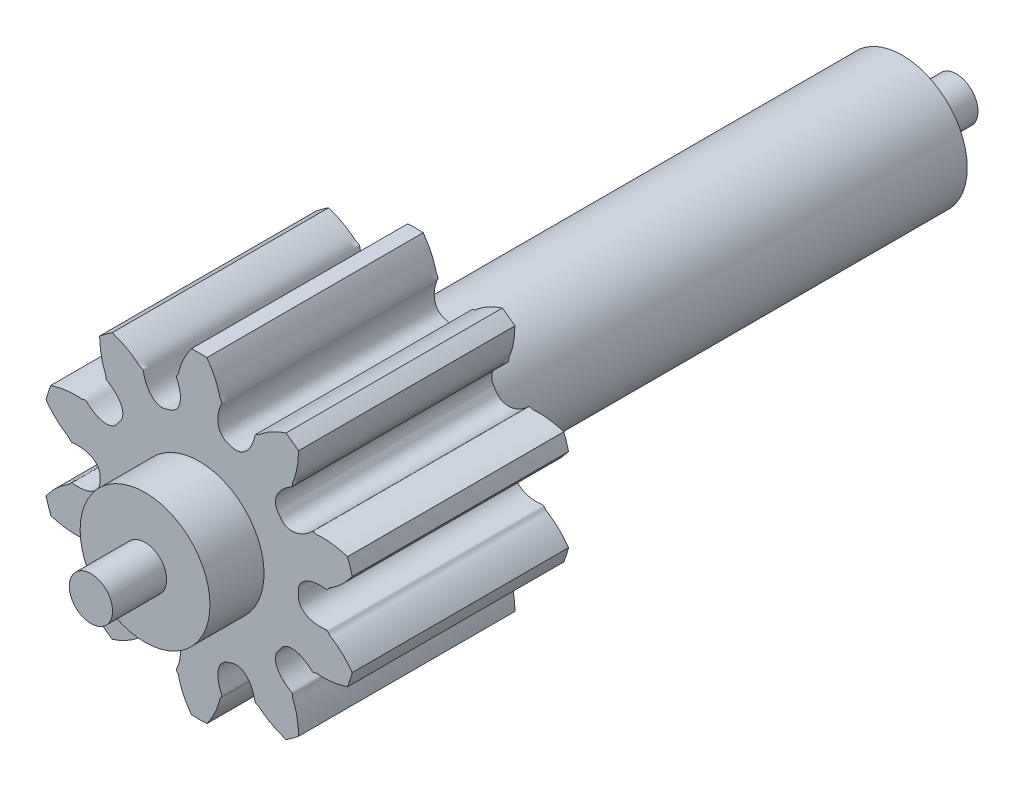
from build123d import *

# Parameters (mm, degrees)
SKETCHREVOLVEENGRANAJE_10D_W       = 1
SKETCHREVOLVEENGRANAJE_10D_H       = 0.733333333
TOOTHEXTRUDECUTENGRANAJE_10D_DEPTH = 0.5
PATTERNENGRANAJE_10D_COUNT         = 10
CROQUIS1_R                         = 0.3
SALIENTE_EXTRUIR1_DEPTH            = 0.25
CROQUIS2_R                         = 0.1
SALIENTE_EXTRUIR2_DEPTH            = 0.25
SALIENTE_EXTRUIR3_START            = 2.25
CROQUIS3_R                         = 0.3
SALIENTE_EXTRUIR3_DEPTH            = 2.25
SALIENTE_EXTRUIR4_START            = 0.25
CROQUIS4_R                         = 0.1
SALIENTE_EXTRUIR4_DEPTH            = 0.25


with BuildPart() as part:
    # SketchRevolveEngranaje 10d → Engranaje 10d (revolve)
    with BuildSketch(Plane(origin=(0, 0, 0), x_dir=(0, 0, -1), z_dir=(1, 0, 0))):
        with Locations((0, 0.366666667)):
            Rectangle(SKETCHREVOLVEENGRANAJE_10D_W, SKETCHREVOLVEENGRANAJE_10D_H)
    revolve(axis=Axis((0, 0, 0), (0, 0, -1)))

    # SketchToothEngranaje 10d → ToothExtrudeCutEngranaje 10d (cut, symmetric)
    with BuildSketch(Plane.XY):
        with BuildLine():
            ThreePointArc((0.712289976, 0.198547415), (0.739444444, 0), (0.712289976, -0.198547415))
            add(Edge.make_bspline(
                [(0.712289976, -0.198547415), (0.705362028, -0.188790946), (0.694695176, -0.174926641), (0.679771555, -0.157850696), (0.669044497, -0.146536064), (0.658544784, -0.136325123), (0.648345251, -0.127175151), (0.638506483, -0.11905948), (0.62911784, -0.11188103), (0.620160338, -0.10576032), (0.611956853, -0.100088888), (0.599411832, -0.094794728), (0.593159303, -0.07860585), (0.580817578, -0.081825839), (0.574358038, -0.082098325), (0.567911869, -0.082518366), (0.561630057, -0.082646483), (0.555476394, -0.082600496), (0.549462764, -0.082353409), (0.543588166, -0.081915249), (0.537854517, -0.081285814), (0.532262567, -0.080466784), (0.526812987, -0.079458409), (0.521506135, -0.078260171), (0.51634221, -0.07687038), (0.511321348, -0.075286016), (0.50644381, -0.073502465), (0.501710247, -0.071513259), (0.497122075, -0.069309806), (0.492682008, -0.06688113), (0.488394785, -0.064213688), (0.484268128, -0.06129133), (0.480313974, -0.058095519), (0.476549972, -0.054605987), (0.473001159, -0.050802046), (0.469701647, -0.04666479), (0.466695797, -0.042180402), (0.464038833, -0.037344546), (0.461793938, -0.03216766), (0.460033669, -0.026679635), (0.45881249, -0.020934905), (0.458302724, -0.015678249), (0.4581106, -0.008685464), (0.458496912, 0), (0.4581106, 0.008685464), (0.458302724, 0.015678249), (0.45881249, 0.020934905), (0.460033669, 0.026679635), (0.461793938, 0.03216766), (0.464038833, 0.037344546), (0.466695797, 0.042180402), (0.469701647, 0.04666479), (0.473001159, 0.050802046), (0.476549972, 0.054605987), (0.480313974, 0.058095519), (0.484268128, 0.06129133), (0.488394785, 0.064213688), (0.492682008, 0.06688113), (0.497122075, 0.069309806), (0.501710247, 0.071513259), (0.50644381, 0.073502465), (0.511321348, 0.075286016), (0.51634221, 0.07687038), (0.521506135, 0.078260171), (0.526812987, 0.079458409), (0.532262567, 0.080466784), (0.537854517, 0.081285814), (0.543588166, 0.081915249), (0.549462764, 0.082353409), (0.555476394, 0.082600496), (0.561630057, 0.082646483), (0.567911869, 0.082518366), (0.574358038, 0.082098325), (0.580817578, 0.081825839), (0.593159303, 0.07860585), (0.599411832, 0.094794728), (0.611956853, 0.100088888), (0.620160338, 0.10576032), (0.62911784, 0.11188103), (0.638506483, 0.11905948), (0.648345251, 0.127175151), (0.658544784, 0.136325123), (0.669044497, 0.146536064), (0.679771555, 0.157850696), (0.694695176, 0.174926641), (0.705362028, 0.188790946), (0.712289976, 0.198547415)],
                knots=[0, 0, 0, 0, 0.051263919, 0.074872303, 0.097131636, 0.118041919, 0.137603151, 0.155815333, 0.172678465, 0.188192546, 0.202357576, 0.215173557, 0.246662628, 0.256263074, 0.265651691, 0.27483298, 0.283811953, 0.292594197, 0.301185954, 0.309594215, 0.317826822, 0.325892584, 0.333801417, 0.341564491, 0.349194395, 0.356705321, 0.364113255, 0.371436161, 0.37869416, 0.385909665, 0.393107425, 0.400314445, 0.407559671, 0.41487336, 0.422285995, 0.42982663, 0.43752059, 0.445386581, 0.453433445, 0.461657142, 0.47003875, 0.478544424, 0.484242756, 0.5, 0.515757244, 0.521455576, 0.52996125, 0.538342858, 0.546566555, 0.554613419, 0.56247941, 0.57017337, 0.577714005, 0.58512664, 0.592440329, 0.599685555, 0.606892575, 0.614090335, 0.62130584, 0.628563839, 0.635886745, 0.643294679, 0.650805605, 0.658435509, 0.666198583, 0.674107416, 0.682173178, 0.690405785, 0.698814046, 0.707405803, 0.716188047, 0.72516702, 0.734348309, 0.743736926, 0.753337372, 0.784826443, 0.797642424, 0.811807454, 0.827321535, 0.844184667, 0.862396849, 0.881958081, 0.902868364, 0.925127697, 0.948736081, 1, 1, 1, 1], degree=3))
        make_face()
    toothextrudecutengranaje_10d = extrude(amount=TOOTHEXTRUDECUTENGRANAJE_10D_DEPTH, both=True, mode=Mode.SUBTRACT)

    # PatternEngranaje 10d: ToothExtrudeCutEngranaje 10d ×10 about axis
    patternengranaje_10d_axis = Axis((0, 0, 55), (0, 0, -1))
    for i in range(1, PATTERNENGRANAJE_10D_COUNT):
        add(toothextrudecutengranaje_10d.rotate(patternengranaje_10d_axis, i * 360 / PATTERNENGRANAJE_10D_COUNT), mode=Mode.SUBTRACT)

    # Croquis1 → Saliente-Extruir1 (add)
    with BuildSketch(Plane.XY.offset(0.5)):
        Circle(CROQUIS1_R)
    extrude(amount=SALIENTE_EXTRUIR1_DEPTH)

    # Croquis2 → Saliente-Extruir2 (add)
    with BuildSketch(Plane.XY.offset(0.75)):
        Circle(CROQUIS2_R)
    extrude(amount=SALIENTE_EXTRUIR2_DEPTH)

    # Croquis3 → Saliente-Extruir3 (add)
    with BuildSketch(Plane(origin=(0, 0, -0.5), x_dir=(-1, 0, 0), z_dir=(0, 0, -1)).offset(SALIENTE_EXTRUIR3_START)):
        Circle(CROQUIS3_R)
    extrude(amount=-SALIENTE_EXTRUIR3_DEPTH)

    # Croquis4 → Saliente-Extruir4 (add)
    with BuildSketch(Plane(origin=(0, 0, -2.75), x_dir=(-1, 0, 0), z_dir=(0, 0, -1)).offset(SALIENTE_EXTRUIR4_START)):
        Circle(CROQUIS4_R)
    extrude(amount=-SALIENTE_EXTRUIR4_DEPTH)


solid = part.part
